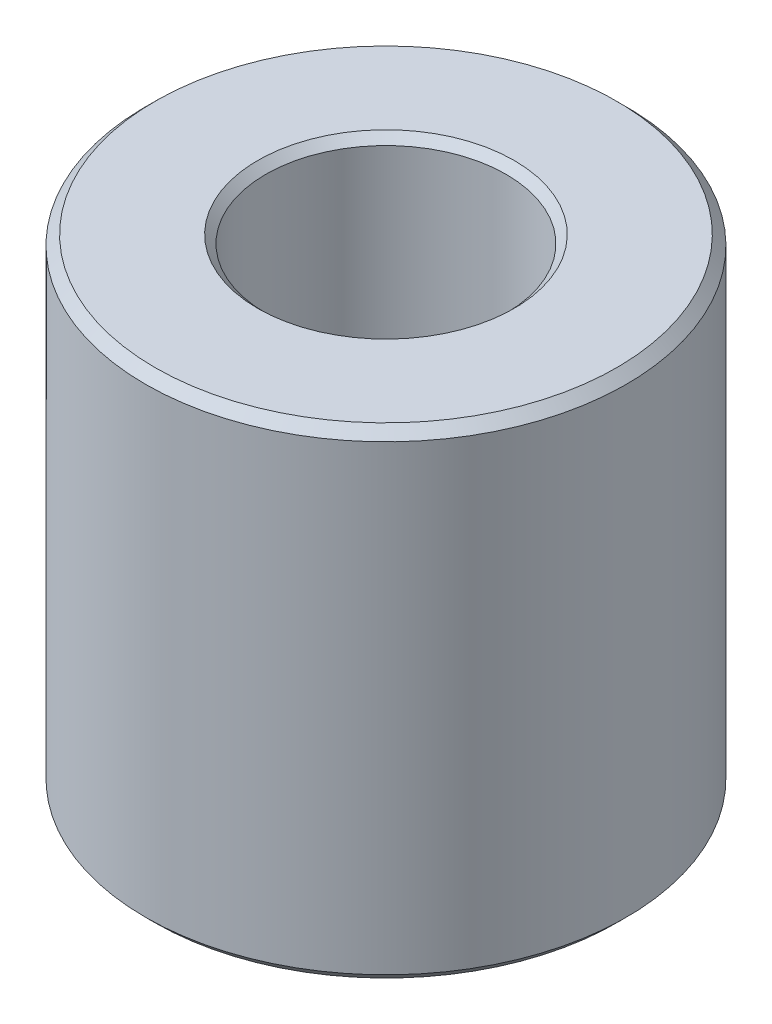
from build123d import *

# Parameters (mm, degrees)
SKETCH1_R      = 19.05
EXTRUDE1_DEPTH = 38.1
CHAMFER1_SIZE  = 0.762


with BuildPart() as part:
    # Sketch1 → Extrude1 (new body)
    with BuildSketch(Plane(origin=(0, 0, 0), x_dir=(1, 0, 0), z_dir=(0, 1, 0))):
        with Locations(Location((0, 0, 0), (0, 0, 270))):  # turned: the seam where the file's is
            Circle(SKETCH1_R)
    extrude(amount=EXTRUDE1_DEPTH)

    # Sketch2 → 3/4 (0.75) Diameter Hole1 (revolve, cut)
    with BuildSketch(Plane(origin=(0, 38.1, 0), x_dir=(0, 0, 1), z_dir=(1, 0, 0))):
        Polygon((0, 0), (0, 38.1), (10.16, 38.1), (9.525, 37.465), (9.525, 0.635), (10.16, 0), align=None)
    revolve(axis=Axis((0, 44.45, 0), (0, -1, 0)), mode=Mode.SUBTRACT)

    # Chamfer1
    chamfer1_edges = [part.edges().sort_by_distance(p)[0] for p in [
        (0, 0, -19.05),
        (0, 38.1, -19.05),
    ]]
    chamfer(chamfer1_edges, length=CHAMFER1_SIZE)


solid = part.part
